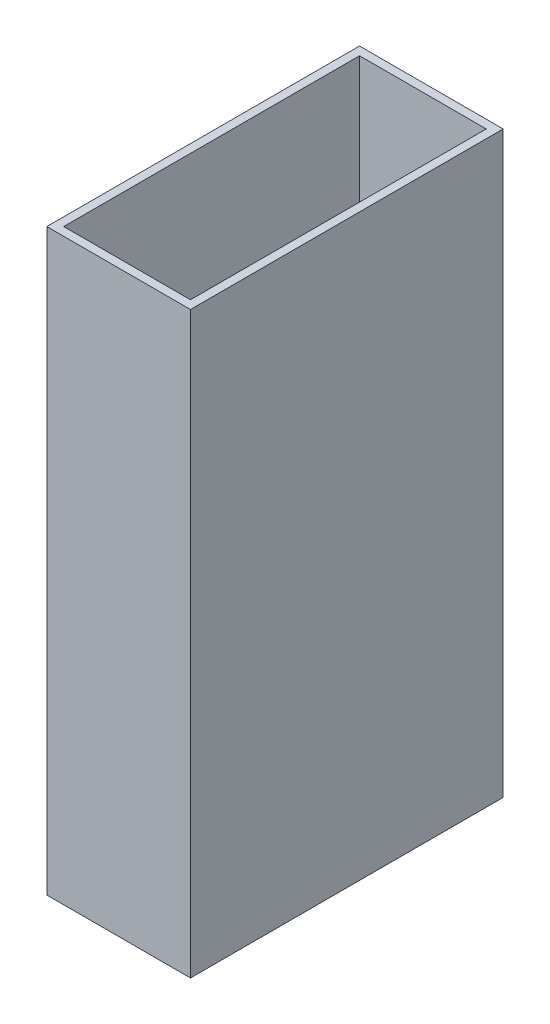
from build123d import *

# Parameters (mm, degrees)
ESQUISSE1_W        = 34
ESQUISSE1_H        = 74
ESQUISSE1_W_2      = 30
ESQUISSE1_H_2      = 70
BOSS_EXTRU_1_DEPTH = 135
ESQUISSE1_2_W      = 34
ESQUISSE1_2_H      = 74
BOSS_EXTRU_2_DEPTH = 2


with BuildPart() as part:
    # Esquisse1 → Boss.-Extru.1 (new body)
    with BuildSketch(Plane(origin=(0, 0, 0), x_dir=(1, 0, 0), z_dir=(0, 1, 0))):
        Rectangle(ESQUISSE1_W, ESQUISSE1_H)
        Rectangle(ESQUISSE1_W_2, ESQUISSE1_H_2, mode=Mode.SUBTRACT)
    extrude(amount=BOSS_EXTRU_1_DEPTH)

    # Esquisse1_2 → Boss.-Extru.2 (add)
    with BuildSketch(Plane(origin=(0, 0, 0), x_dir=(1, 0, 0), z_dir=(0, 1, 0))):
        Rectangle(ESQUISSE1_2_W, ESQUISSE1_2_H)
    extrude(amount=-BOSS_EXTRU_2_DEPTH)


solid = part.part
